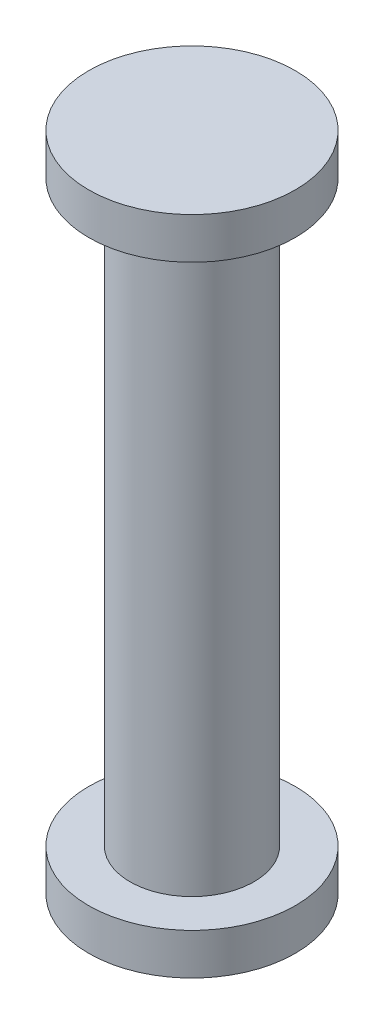
from build123d import *


with BuildPart() as part:
    # Sketch1 → Revolve1 (revolve)
    with BuildSketch(Plane.XY):
        Polygon((0, 0), (0, 16), (-2.5, 16), (-2.5, 15), (-1.5, 15), (-1.5, 1), (-2.5, 1), (-2.5, 0), align=None)
    revolve(axis=Axis((0, 0, 0), (0, 1, 0)))


solid = part.part
